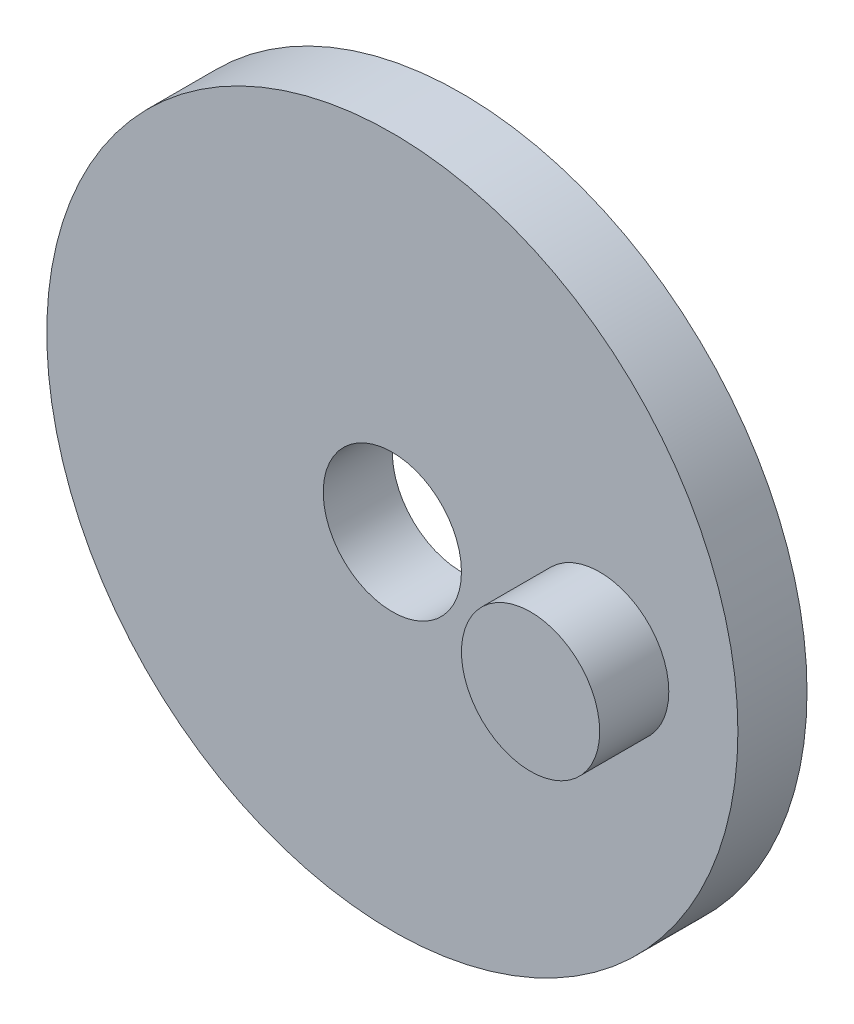
from build123d import *

# Parameters (mm, degrees)
SKETCH1_R           = 50
SKETCH1_R_2         = 10
BOSS_EXTRUDE1_DEPTH = 10
SKETCH1_2_R         = 10
BOSS_EXTRUDE2_DEPTH = 20


with BuildPart() as part:
    # Sketch1 → Boss-Extrude1 (new body)
    with BuildSketch(Plane.XY):
        Circle(SKETCH1_R)
        with Locations((30, 0)):
            Circle(SKETCH1_R_2, mode=Mode.SUBTRACT)
        Circle(SKETCH1_R_2, mode=Mode.SUBTRACT)
    extrude(amount=BOSS_EXTRUDE1_DEPTH)

    # Sketch1_2 → Boss-Extrude2 (add)
    with BuildSketch(Plane.XY):
        with Locations((30, 0)):
            Circle(SKETCH1_2_R)
    extrude(amount=BOSS_EXTRUDE2_DEPTH)


solid = part.part
